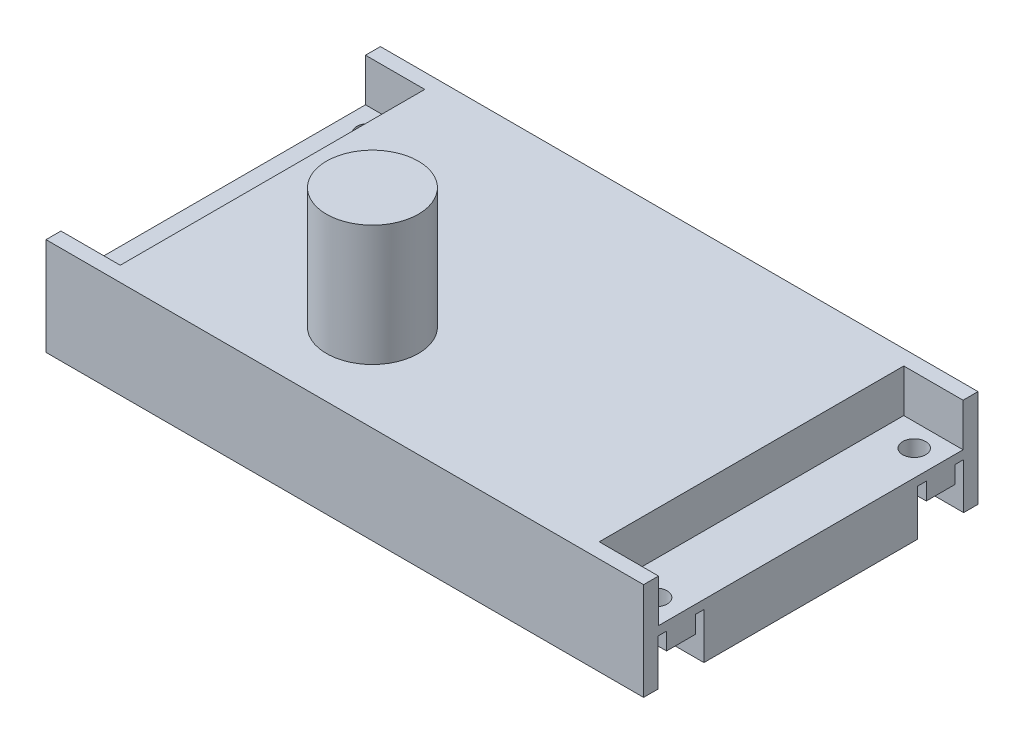
from build123d import *

# Parameters (mm, degrees)
SKETCH1_W             = 104
SKETCH1_H             = 58.2
BOSS_EXTRUDE1_DEPTH   = 17
CUT_EXTRUDE2_DEPTH    = 105
SKETCH3_R             = 8
BOSS_EXTRUDE2_DEPTH   = 21
F_4_0MM_DOWEL_HOLE1_D = 4
SKETCH6_W             = 53
SKETCH6_H             = 7.475
CUT_EXTRUDE3_DEPTH    = 10.31875


with BuildPart() as part:
    # Sketch1 → Boss-Extrude1 (new body)
    with BuildSketch(Plane(origin=(0, 0, 0), x_dir=(1, 0, 0), z_dir=(0, 1, 0))):
        with Locations((52, 29.1)):
            Rectangle(SKETCH1_W, SKETCH1_H)
    extrude(amount=BOSS_EXTRUDE1_DEPTH)

    # Sketch2 → Cut-Extrude2 (cut, through all)
    with BuildSketch(Plane(origin=(104, 0, 0), x_dir=(0, 0, -1), z_dir=(1, 0, 0))):
        Polygon((2.5, 0), (2.5, 8), (4, 8), (4, 5), (9, 5), (9, 8), (10.5, 8), (10.5, 0), align=None)
        Polygon((47.7, 8), (47.7, 0), (55.7, 0), (55.7, 8), (54.2, 8), (54.2, 5), (49.2, 5), (49.2, 8), align=None)
    extrude(amount=-CUT_EXTRUDE2_DEPTH, mode=Mode.SUBTRACT)

    # Sketch3 → Boss-Extrude2 (add)
    with BuildSketch(Plane(origin=(0, 17, 0), x_dir=(1, 0, 0), z_dir=(0, 1, 0))):
        with Locations((41.573485345, 15.236601424)):
            Circle(SKETCH3_R)
    extrude(amount=BOSS_EXTRUDE2_DEPTH)

    # Ø4.0mm Dowel Hole1 (through all)
    with Locations(Plane(origin=(0, 5, 0), x_dir=(-1, 0, 0), z_dir=(0, -1, 0))):
        with Locations((-4.5, 51.6), (-4.5, 6.6), (-99.5, 6.6), (-99.5, 51.6)):
            Hole(F_4_0MM_DOWEL_HOLE1_D / 2)

    # Sketch6 → Cut-Extrude3 (cut)
    with BuildSketch(Plane(origin=(104, 0, 0), x_dir=(0, 0, -1), z_dir=(1, 0, 0))):
        with Locations((29.1, 13.2625)):
            Rectangle(SKETCH6_W, SKETCH6_H)
    cut_extrude3 = extrude(amount=-CUT_EXTRUDE3_DEPTH, mode=Mode.SUBTRACT)

    # Mirror1: Cut-Extrude3 across plane
    add(cut_extrude3.mirror(Plane.ZY.offset(-52.00000014)), mode=Mode.SUBTRACT)


solid = part.part
